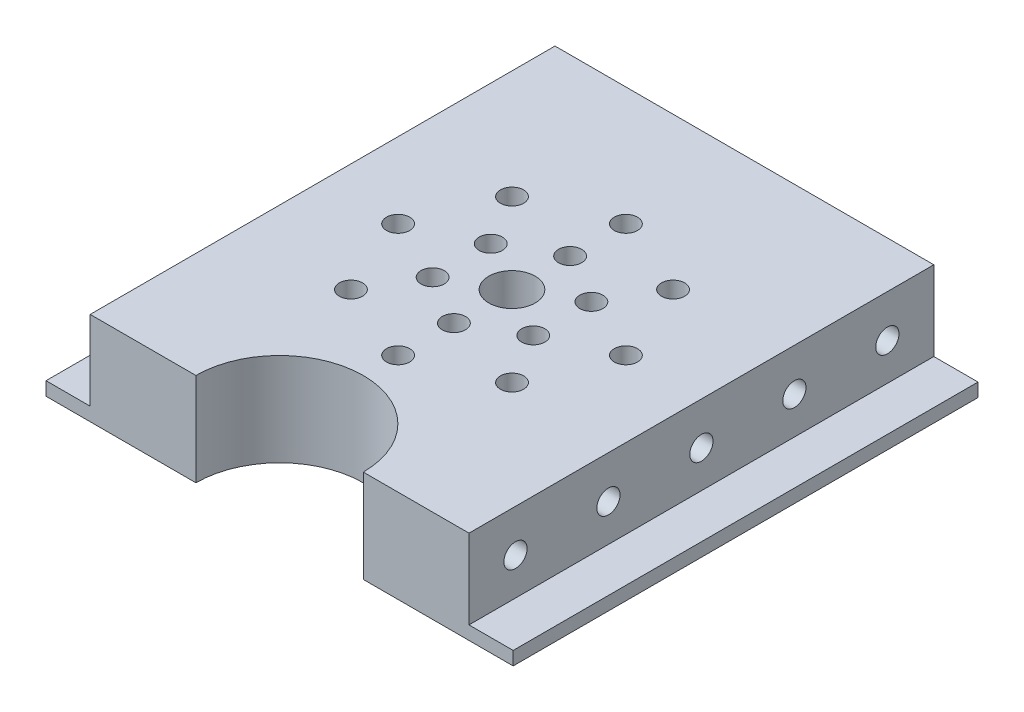
from build123d import *

# Parameters (mm, degrees)
ESQUISSE1_W             = 100.5
ESQUISSE1_H             = 100
BOSS_EXTRU_1_DEPTH      = 20
ESQUISSE2_W             = 9.5
ESQUISSE2_H             = 100
ENL_V_MAT_EXTRU_1_DEPTH = 17.1
ESQUISSE3_R             = 2.5
ENL_V_MAT_EXTRU_2_DEPTH = 16
ESQUISSE4_R             = 2.5
ENL_V_MAT_EXTRU_3_DEPTH = 16
ESQUISSE5_R             = 2.5
ENL_V_MAT_EXTRU_4_DEPTH = 21
ESQUISSE6_R             = 5
ENL_V_MAT_EXTRU_5_DEPTH = 21
ESQUISSE7_R             = 30
ENL_V_MAT_EXTRU_6_DEPTH = 4
ESQUISSE8_R             = 19
ENL_V_MAT_EXTRU_7_DEPTH = 4
ESQUISSE9_R             = 2.5
ENL_V_MAT_EXTRU_8_DEPTH = 13
ESQUISSE11_R            = 18
ENL_V_MAT_EXTRU_9_DEPTH = 21


with BuildPart() as part:
    # Esquisse1 → Boss.-Extru.1 (new body)
    with BuildSketch(Plane(origin=(0, 0, 0), x_dir=(1, 0, 0), z_dir=(0, 1, 0))):
        Rectangle(ESQUISSE1_W, ESQUISSE1_H)
    extrude(amount=BOSS_EXTRU_1_DEPTH)

    # Esquisse2 → Enlèv. mat.-Extru.1 (cut)
    with BuildSketch(Plane(origin=(0, 20, 0), x_dir=(1, 0, 0), z_dir=(0, 1, 0))):
        with Locations((45.5, 0)):
            Rectangle(ESQUISSE2_W, ESQUISSE2_H)
        with Locations((-45.5, 0)):
            Rectangle(ESQUISSE2_W, ESQUISSE2_H)
    extrude(amount=-ENL_V_MAT_EXTRU_1_DEPTH, mode=Mode.SUBTRACT)

    # Esquisse3 → Enlèv. mat.-Extru.2 (cut)
    with BuildSketch(Plane.ZY.offset(40.75)):
        with Locations((-40, 10.9)):
            Circle(ESQUISSE3_R)
        with Locations((-20, 10.9)):
            Circle(ESQUISSE3_R)
        with Locations((0, 10.9)):
            Circle(ESQUISSE3_R)
        with Locations((20, 10.9)):
            Circle(ESQUISSE3_R)
        with Locations((40, 10.9)):
            Circle(ESQUISSE3_R)
    extrude(amount=-ENL_V_MAT_EXTRU_2_DEPTH, mode=Mode.SUBTRACT)

    # Esquisse4 → Enlèv. mat.-Extru.3 (cut)
    with BuildSketch(Plane(origin=(40.75, 0, 0), x_dir=(0, 0, -1), z_dir=(1, 0, 0))):
        with Locations((-20, 10.9)):
            Circle(ESQUISSE4_R)
        with Locations((0, 10.9)):
            Circle(ESQUISSE4_R)
        with Locations((20, 10.9)):
            Circle(ESQUISSE4_R)
        with Locations((40, 10.9)):
            Circle(ESQUISSE4_R)
        with Locations((-40, 10.9)):
            Circle(ESQUISSE4_R)
    extrude(amount=-ENL_V_MAT_EXTRU_3_DEPTH, mode=Mode.SUBTRACT)

    # Esquisse5 → Enlèv. mat.-Extru.4 (cut, through all)
    with BuildSketch(Plane(origin=(0, 20, 0), x_dir=(1, 0, 0), z_dir=(0, 1, 0))):
        with Locations((0, -24.5)):
            Circle(ESQUISSE5_R)
        with Locations((-17.324116139, -17.324116139)):
            Circle(ESQUISSE5_R)
        with Locations((-24.5, 0)):
            Circle(ESQUISSE5_R)
        with Locations((-17.324116139, 17.324116139)):
            Circle(ESQUISSE5_R)
        with Locations((0, 24.5)):
            Circle(ESQUISSE5_R)
        with Locations((17.324116139, 17.324116139)):
            Circle(ESQUISSE5_R)
        with Locations((24.5, 0)):
            Circle(ESQUISSE5_R)
        with Locations((17.324116139, -17.324116139)):
            Circle(ESQUISSE5_R)
    extrude(amount=-ENL_V_MAT_EXTRU_4_DEPTH, mode=Mode.SUBTRACT)

    # Esquisse6 → Enlèv. mat.-Extru.5 (cut, through all)
    with BuildSketch(Plane(origin=(0, 20, 0), x_dir=(1, 0, 0), z_dir=(0, 1, 0))):
        Circle(ESQUISSE6_R)
    extrude(amount=-ENL_V_MAT_EXTRU_5_DEPTH, mode=Mode.SUBTRACT)

    # Esquisse7 → Enlèv. mat.-Extru.6 (cut)
    with BuildSketch(Plane.XZ):
        Circle(ESQUISSE7_R)
    extrude(amount=-ENL_V_MAT_EXTRU_6_DEPTH, mode=Mode.SUBTRACT)

    # Esquisse8 → Enlèv. mat.-Extru.7 (cut)
    with BuildSketch(Plane.XZ.offset(-4)):
        Circle(ESQUISSE8_R)
    extrude(amount=-ENL_V_MAT_EXTRU_7_DEPTH, mode=Mode.SUBTRACT)

    # Esquisse9 → Enlèv. mat.-Extru.8 (cut, through all)
    with BuildSketch(Plane.XZ.offset(-8)):
        with Locations((0, -12.5)):
            Circle(ESQUISSE9_R)
        with Locations((-10.825317547, -6.25)):
            Circle(ESQUISSE9_R)
        with Locations((-10.825317547, 6.25)):
            Circle(ESQUISSE9_R)
        with Locations((0, 12.5)):
            Circle(ESQUISSE9_R)
        with Locations((10.825317547, 6.25)):
            Circle(ESQUISSE9_R)
        with Locations((10.825317547, -6.25)):
            Circle(ESQUISSE9_R)
    extrude(amount=-ENL_V_MAT_EXTRU_8_DEPTH, mode=Mode.SUBTRACT)

    # Esquisse11 → Enlèv. mat.-Extru.9 (cut, through all)
    with BuildSketch(Plane(origin=(0, 20, 0), x_dir=(1, 0, 0), z_dir=(0, 1, 0))):
        with Locations((0, -50)):
            Circle(ESQUISSE11_R)
    extrude(amount=-ENL_V_MAT_EXTRU_9_DEPTH, mode=Mode.SUBTRACT)


solid = part.part
